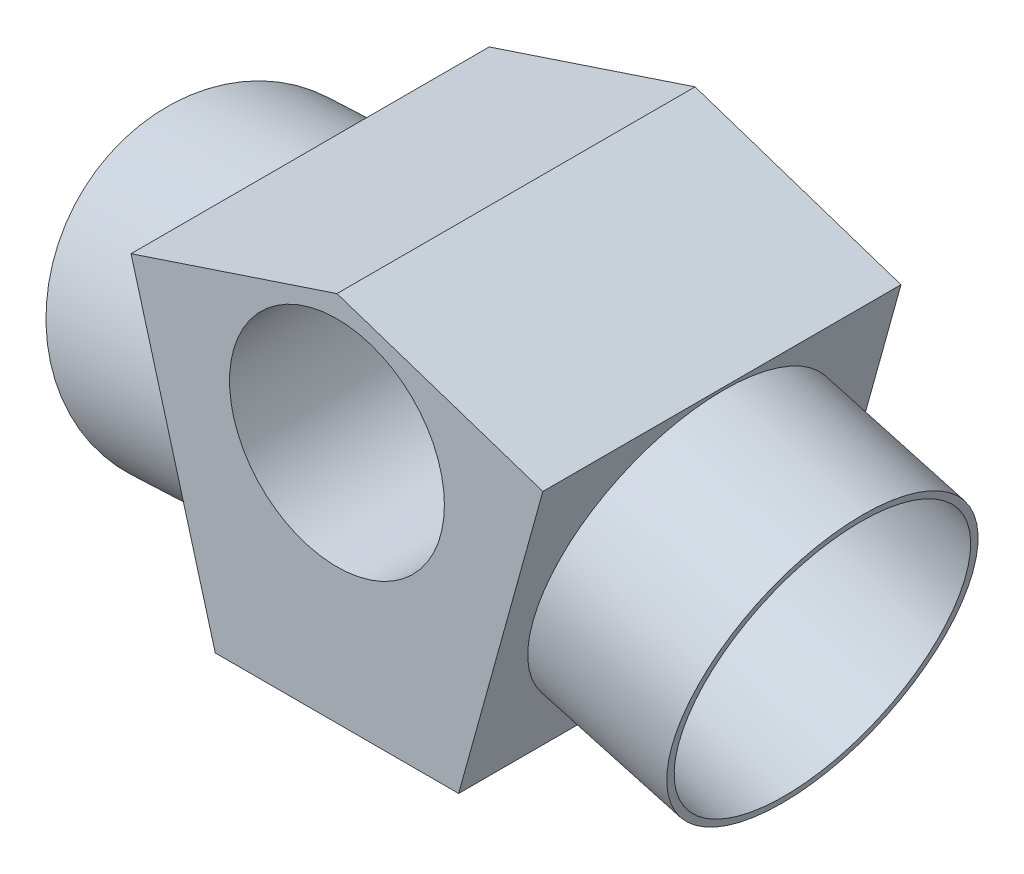
from build123d import *

# Parameters (mm, degrees)
SKETCH2_R                = 7.5
BOSS_EXTRUDE1_DEPTH      = 25
SKETCH14_R               = 10.5
SKETCH14_R_2             = 10
EXTRUDE_THIN3_DEPTH      = 3
EXTRUDE_THIN3_DEPTH_BACK = 12
SKETCH8_R                = 10
CUT_EXTRUDE4_DEPTH       = 13
SKETCH12_R               = 10.5
SKETCH12_R_2             = 10
EXTRUDE_THIN2_DEPTH      = 12


with BuildPart() as part:
    # Sketch2 → Boss-Extrude1 (new body)
    with BuildSketch(Plane.XY):
        Polygon((0, 9.022413356), (-14.374271139, 4.248669099), (-8.495026865, -16.951200871), (8.495026865, -16.951200871), (14.374271139, 4.248669099), align=None)
        Circle(SKETCH2_R, mode=Mode.SUBTRACT)
    extrude(amount=-BOSS_EXTRUDE1_DEPTH)

    # Sketch14 → Extrude-Thin3 (add, two sides)
    with BuildSketch(Plane(origin=(-8.98162527, -2.490825133, 2.158943025), x_dir=(0.267238376, -0.963630453, 0), z_dir=(0.938775452, 0.260345474, -0.225656566))) as extrude_thin3_sk:
        with Locations((3.064496194, 15.047052931)):
            Circle(SKETCH14_R)
        with Locations((3.064496194, 15.047052931)):
            Circle(SKETCH14_R_2, mode=Mode.SUBTRACT)
    extrude(amount=EXTRUDE_THIN3_DEPTH)
    extrude(extrude_thin3_sk.sketch, amount=-EXTRUDE_THIN3_DEPTH_BACK)

    # Sketch8 → Cut-Extrude4 (cut)
    with BuildSketch(Plane(origin=(21.957149201, -6.089256391, 0), x_dir=(0, 0, -1), z_dir=(0.963630453, -0.267238376, 0))):
        with Locations((12.31580825, -2.819568794)):
            Circle(SKETCH8_R)
    extrude(amount=-CUT_EXTRUDE4_DEPTH, mode=Mode.SUBTRACT)

    # Sketch12 → Extrude-Thin2 (add)
    with BuildSketch(Plane(origin=(21.957149201, -6.089256391, 0), x_dir=(0, 0, -1), z_dir=(0.963630453, -0.267238376, 0))):
        with Locations((12.31580825, -2.819568794)):
            Circle(SKETCH12_R)
        with Locations((12.31580825, -2.819568794)):
            Circle(SKETCH12_R_2, mode=Mode.SUBTRACT)
    extrude(amount=-EXTRUDE_THIN2_DEPTH)


with BuildPart() as body_2:
    # Mirror1: mirrored copy
    add(part.part.mirror(Plane(origin=(0, 0, -25), x_dir=(1, 0, 0), z_dir=(0, 0, -1))))


solid = body_2.part
